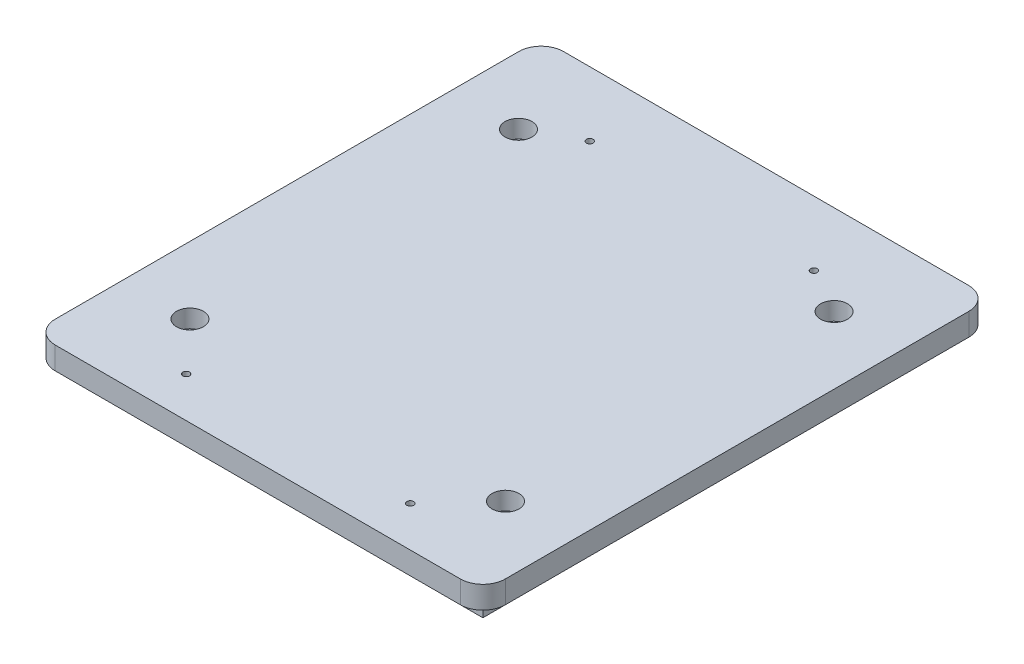
from build123d import *

# Parameters (mm, degrees)
SKETCH1_W           = 100.4
SKETCH1_H           = 113.4
BOSS_EXTRUDE1_DEPTH = 5
SKETCH2_W           = 90.4
SKETCH2_H           = 103.4
BOSS_EXTRUDE2_DEPTH = 5
FILLET1_R           = 5
SKETCH3_R           = 1.5
CUT_EXTRUDE1_DEPTH  = 17
SKETCH4_R           = 3
CUT_EXTRUDE2_DEPTH  = 4
SKETCH5_R           = 0.75
CUT_EXTRUDE3_DEPTH  = 19


with BuildPart() as part:
    # Sketch1 → Boss-Extrude1 (new body)
    with BuildSketch(Plane(origin=(0, 0, 0), x_dir=(1, 0, 0), z_dir=(0, 1, 0))):
        Rectangle(SKETCH1_W, SKETCH1_H)
    extrude(amount=BOSS_EXTRUDE1_DEPTH)

    # Sketch2 → Boss-Extrude2 (add)
    with BuildSketch(Plane.XZ):
        Rectangle(SKETCH2_W, SKETCH2_H)
    extrude(amount=BOSS_EXTRUDE2_DEPTH)

    # Fillet1
    fillet1_edges = [part.edges().sort_by_distance(p)[0] for p in [
        (50.2, 2.5, 56.7),
        (-50.2, 2.5, 56.7),
        (-50.2, 2.5, -56.7),
        (50.2, 2.5, -56.7),
    ]]
    fillet(fillet1_edges, radius=FILLET1_R)

    # Sketch3 → Cut-Extrude1 (cut)
    with BuildSketch(Plane(origin=(0, 5, 0), x_dir=(1, 0, 0), z_dir=(0, 1, 0))):
        with Locations((-35.2, 36.65)):
            Circle(SKETCH3_R)
        with Locations((-35.2, -36.65)):
            Circle(SKETCH3_R)
        with Locations((35.2, 36.65)):
            Circle(SKETCH3_R)
        with Locations((35.2, -36.65)):
            Circle(SKETCH3_R)
    extrude(amount=-CUT_EXTRUDE1_DEPTH, mode=Mode.SUBTRACT)

    # Sketch4 → Cut-Extrude2 (cut)
    with BuildSketch(Plane(origin=(0, 5, 0), x_dir=(1, 0, 0), z_dir=(0, 1, 0))):
        with Locations((-35.2, 36.65)):
            Circle(SKETCH4_R)
        with Locations((-35.2, -36.65)):
            Circle(SKETCH4_R)
        with Locations((35.2, 36.65)):
            Circle(SKETCH4_R)
        with Locations((35.2, -36.65)):
            Circle(SKETCH4_R)
    extrude(amount=-CUT_EXTRUDE2_DEPTH, mode=Mode.SUBTRACT)

    # Sketch5 → Cut-Extrude3 (cut)
    with BuildSketch(Plane(origin=(0, 5, 0), x_dir=(1, 0, 0), z_dir=(0, 1, 0))):
        with Locations((-24.945666125, 42.299983599)):
            Circle(SKETCH5_R)
        with Locations((-25, -47.7)):
            Circle(SKETCH5_R)
        with Locations((25.054333875, 42.299983599)):
            Circle(SKETCH5_R)
        with Locations((25, -47.7)):
            Circle(SKETCH5_R)
    extrude(amount=-CUT_EXTRUDE3_DEPTH, mode=Mode.SUBTRACT)


solid = part.part
